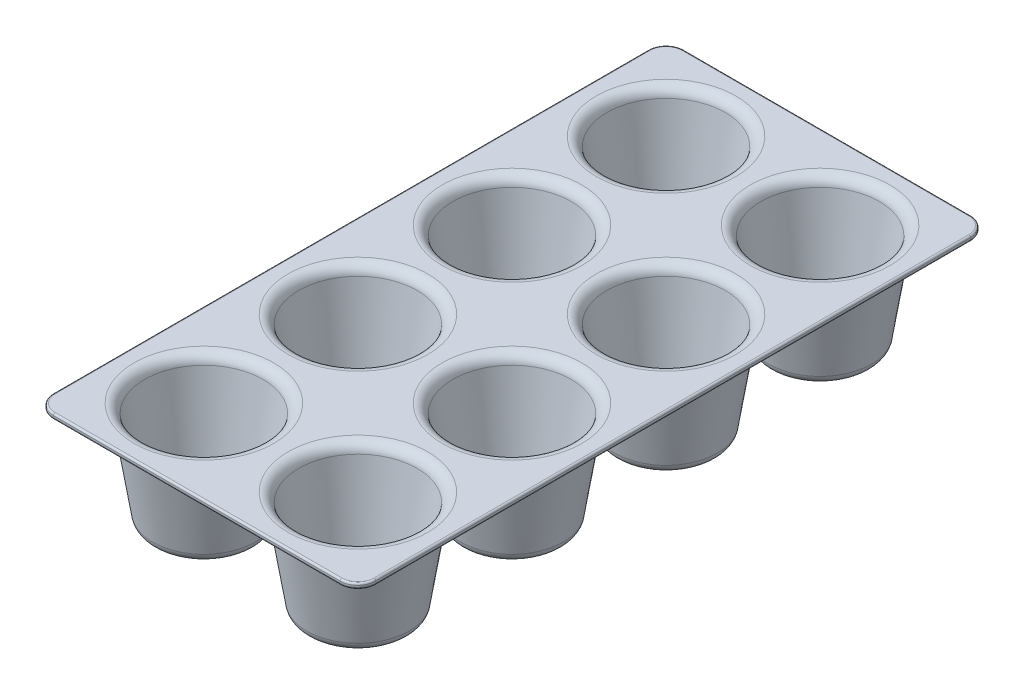
from build123d import *

# Parameters (mm, degrees)
BOSS_EXTRUDE1_DEPTH  = 3
FILLET1_R            = 1
LPATTERN1_COUNT      = 2
LPATTERN1_PITCH      = 86
LPATTERN1_COUNT_DIR2 = 4
LPATTERN1_PITCH_DIR2 = 86


with BuildPart() as part:
    # Sketch1 → Revolve1 (revolve)
    with BuildSketch(Plane.XY):
        with BuildLine():
            Line((-22.602129613, -55), (0, -55))
            Line((0, -55), (0, -52))
            Line((0, -52), (-22.602129613, -52))
            ThreePointArc((-22.602129613, -52), (-24.550473758, -51.281217897), (-25.565194635, -49.469303395))
            Line((-25.565194635, -49.469303395), (-33.073869956, -2.06139321))
            ThreePointArc((-33.073869956, -2.06139321), (-35.10331171, 1.562435794), (-39, 3))
            Line((-39, 3), (-39, 0))
            ThreePointArc((-39, 0), (-37.051655855, -0.718782103), (-36.036934978, -2.530696605))
            Line((-36.036934978, -2.530696605), (-28.528259657, -49.93860679))
            ThreePointArc((-28.528259657, -49.93860679), (-26.498817903, -53.562435794), (-22.602129613, -55))
        make_face()
    revolve1 = revolve(axis=Axis((0, -55, 0), (0, 1, 0)))

    # Sketch2 → Boss-Extrude1 (add)
    with BuildSketch(Plane(origin=(0, 3, 0), x_dir=(-1, 0, 0), z_dir=(0, -1, 0))):
        with BuildLine():
            Line((-37, 47), (123, 47))
            ThreePointArc((123, 47), (130.071067812, 44.071067812), (133, 37))
            Line((133, 37), (133, -295))
            ThreePointArc((133, -295), (130.071067812, -302.071067812), (123, -305))
            Line((123, -305), (-37, -305))
            ThreePointArc((-37, -305), (-44.071067812, -302.071067812), (-47, -295))
            Line((-47, -295), (-47, 37))
            ThreePointArc((-47, 37), (-44.071067812, 44.071067812), (-37, 47))
        make_face()
    extrude(amount=BOSS_EXTRUDE1_DEPTH)

    # Fillet1
    fillet1_edges = [part.edges().sort_by_distance(p)[0] for p in [
        (44.071067812, 0, -44.071067812),
        (-43, 0, -47),
        (-130.071067812, 0, -44.071067812),
        (-133, 0, 129),
        (-130.071067812, 0, 302.071067812),
        (-43, 0, 305),
        (44.071067812, 0, 302.071067812),
        (44.071067812, 3, -44.071067812),
        (-43, 3, -47),
        (-130.071067812, 3, -44.071067812),
        (-133, 3, 129),
        (-130.071067812, 3, 302.071067812),
        (-43, 3, 305),
        (44.071067812, 3, 302.071067812),
        (47, 0, 129),
        (47, 3, 129),
    ]]
    fillet(fillet1_edges, radius=FILLET1_R)

    # Sketch1_5 → Cut-Revolve2 (revolve, cut)
    with BuildSketch(Plane.XY):
        with BuildLine():
            Line((-22.602129613, -52), (0, -52))
            Line((0, -52), (0, 3))
            Line((0, 3), (-39, 3))
            ThreePointArc((-39, 3), (-35.10331171, 1.562435794), (-33.073869956, -2.06139321))
            Line((-33.073869956, -2.06139321), (-25.565194635, -49.469303395))
            ThreePointArc((-25.565194635, -49.469303395), (-24.550473758, -51.281217897), (-22.602129613, -52))
        make_face()
    cut_revolve2 = revolve(axis=Axis((0, 0, 0), (0, -1, 0)), mode=Mode.SUBTRACT)

    # LPattern1: Revolve1, Cut-Revolve2 2 × 4
    with Locations(*[(-i * LPATTERN1_PITCH, 0, j * LPATTERN1_PITCH_DIR2) for i in range(LPATTERN1_COUNT) for j in range(LPATTERN1_COUNT_DIR2) if (i, j) != (0, 0)]):
        add(revolve1)
        add(cut_revolve2, mode=Mode.SUBTRACT)


solid = part.part
